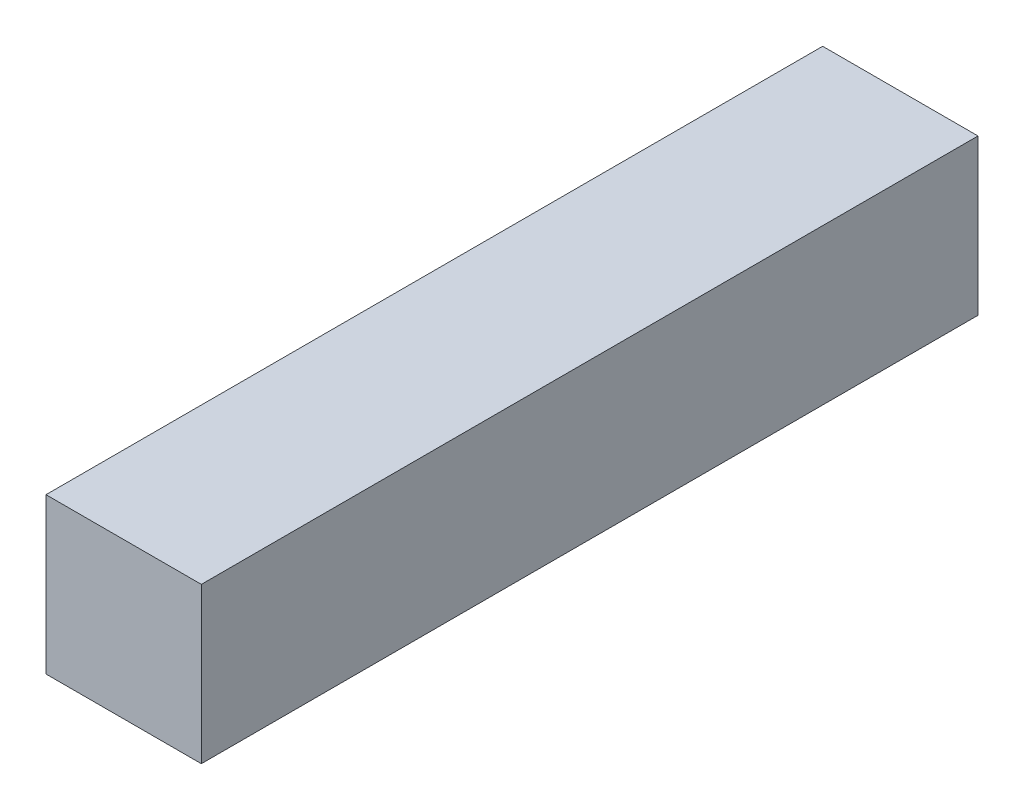
from build123d import *

# Parameters (mm, degrees)
SKETCH1_W           = 6.35
SKETCH1_H           = 6.35
BOSS_EXTRUDE1_DEPTH = 31.75


with BuildPart() as part:
    # Sketch1 → Boss-Extrude1 (new body)
    with BuildSketch(Plane.XY):
        Rectangle(SKETCH1_W, SKETCH1_H)
    extrude(amount=BOSS_EXTRUDE1_DEPTH)


solid = part.part
